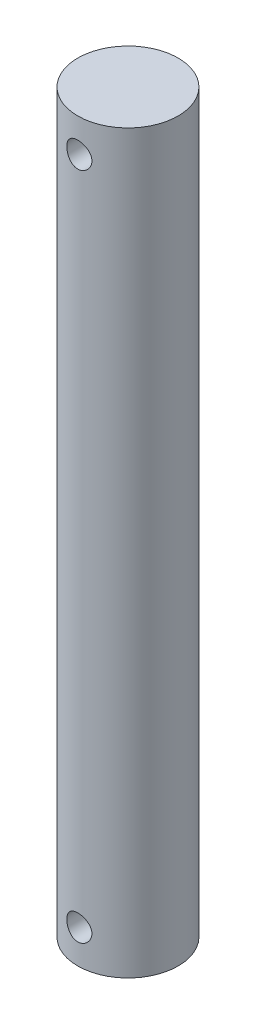
from build123d import *

# Parameters (mm, degrees)
SKETCH1_R               = 19.05
BOSS_EXTRUDE1_DEPTH     = 279.4
SKETCH2_R               = 4.7625
CUT_EXTRUDE1_DEPTH      = 20.05
CUT_EXTRUDE1_DEPTH_BACK = 20.05


with BuildPart() as part:
    # Sketch1 → Boss-Extrude1 (new body)
    with BuildSketch(Plane(origin=(0, 0, 0), x_dir=(1, 0, 0), z_dir=(0, 1, 0))):
        Circle(SKETCH1_R)
    extrude(amount=BOSS_EXTRUDE1_DEPTH)

    # Sketch2 → Cut-Extrude1 (cut, two sides)
    with BuildSketch(Plane.XY) as cut_extrude1_sk:
        with Locations((0, 266.7)):
            Circle(SKETCH2_R)
        with Locations((0, 12.7)):
            Circle(SKETCH2_R)
    extrude(amount=CUT_EXTRUDE1_DEPTH, mode=Mode.SUBTRACT)
    extrude(cut_extrude1_sk.sketch, amount=-CUT_EXTRUDE1_DEPTH_BACK, mode=Mode.SUBTRACT)


solid = part.part
